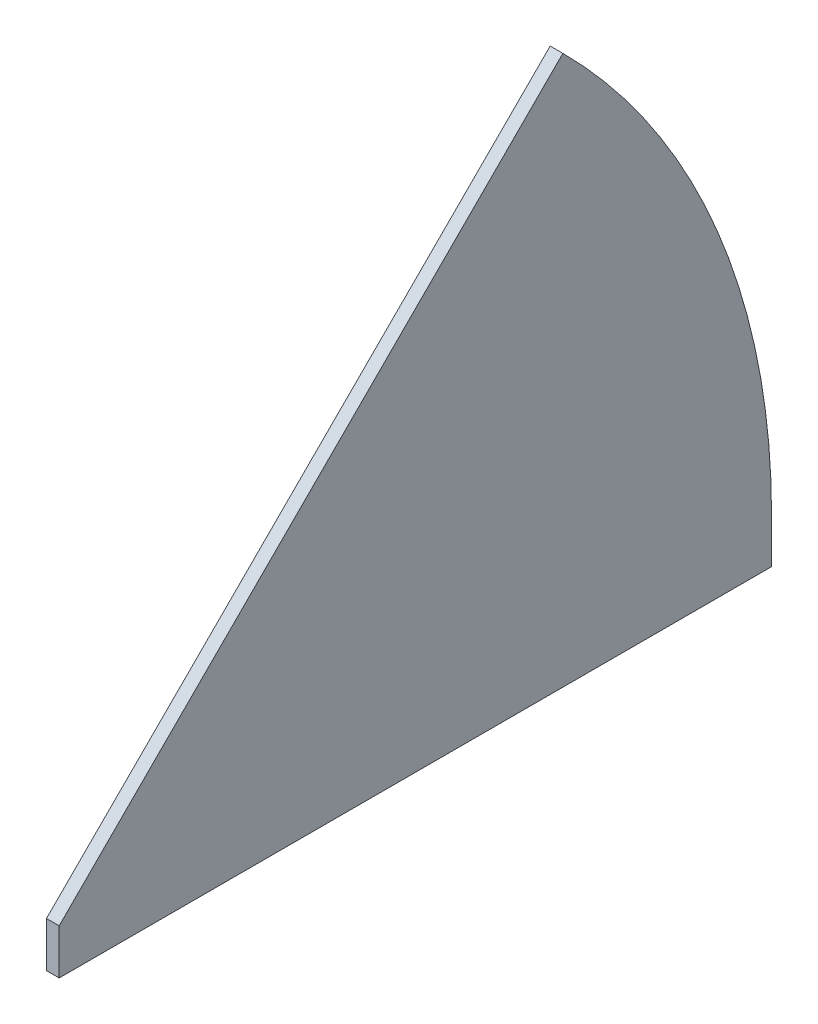
from build123d import *

# Parameters (mm, degrees)
BOSS_EXTRUDE1_DEPTH = 3.175
SKETCH2_W           = 3.175
SKETCH2_H           = 178.054
BOSS_EXTRUDE2_DEPTH = 11.303


with BuildPart() as part:
    # Sketch1 → Boss-Extrude1 (new body)
    with BuildSketch(Plane(origin=(0, 0, 0), x_dir=(0, 0, -1), z_dir=(1, 0, 0))):
        with BuildLine():
            Line((0, 0), (178.054, 0))
            ThreePointArc((178.054, 0), (164.500446282, 68.138315866), (125.903190817, 125.903190817))
            Line((125.903190817, 125.903190817), (0, 0))
        make_face()
    extrude(amount=BOSS_EXTRUDE1_DEPTH)

    # Sketch2 → Boss-Extrude2 (add)
    with BuildSketch(Plane.XZ):
        with Locations((1.5875, -89.027)):
            Rectangle(SKETCH2_W, SKETCH2_H)
    extrude(amount=BOSS_EXTRUDE2_DEPTH)


solid = part.part
